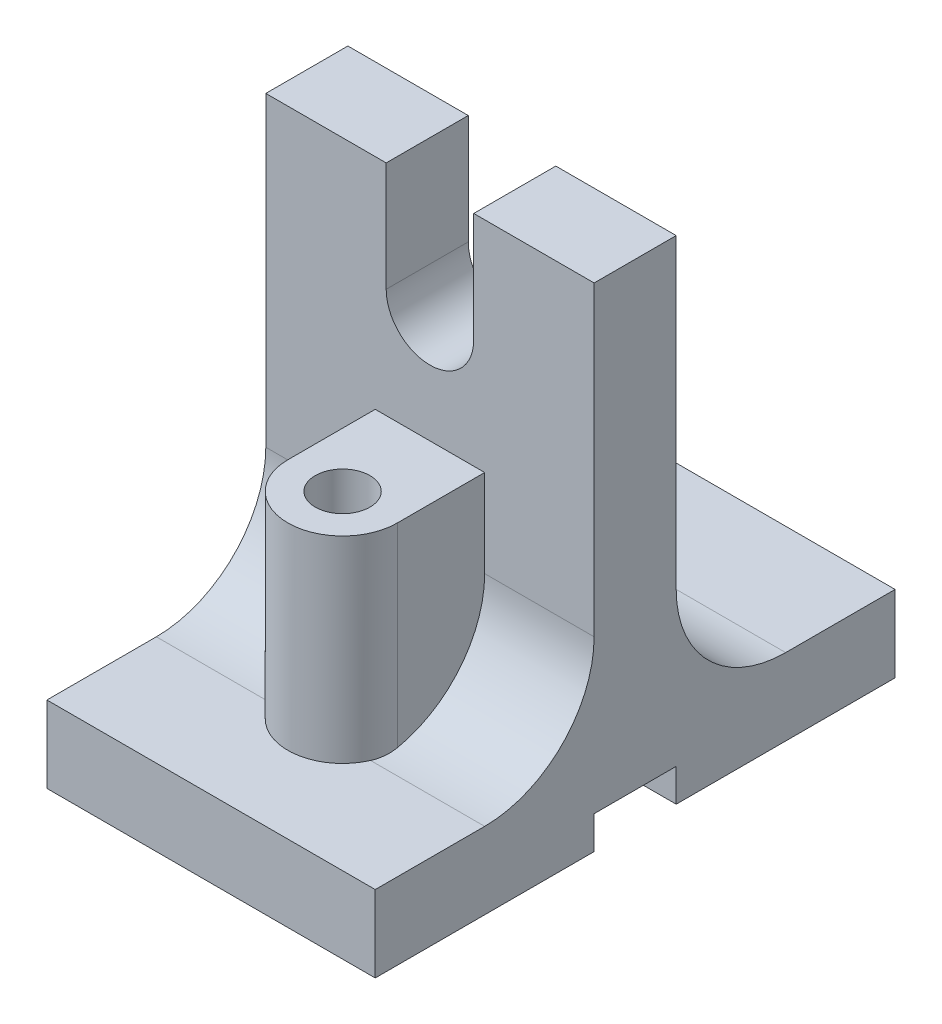
from build123d import *

# Parameters (mm, degrees)
BOSS_EXTRUDE1_DEPTH = 30
CUT_EXTRUDE1_DEPTH  = 60
SKETCH6_R           = 5
BOSS_EXTRUDE2_DEPTH = 36


with BuildPart() as part:
    # Sketch4 → Boss-Extrude1 (new body, symmetric)
    with BuildSketch(Plane(origin=(0, 0, 0), x_dir=(0, 0, -1), z_dir=(1, 0, 0))):
        with BuildLine():
            Line((-7.5, 90), (7.5, 90))
            Line((7.5, 90), (7.5, 34))
            ThreePointArc((7.5, 34), (13.357864376, 19.857864376), (27.5, 14))
            Line((27.5, 14), (47.5, 14))
            Line((47.5, 14), (47.5, 0))
            Line((47.5, 0), (7.5, 0))
            Line((7.5, 0), (7.5, 6))
            Line((7.5, 6), (-7.5, 6))
            Line((-7.5, 6), (-7.5, 0))
            Line((-7.5, 0), (-47.5, 0))
            Line((-47.5, 0), (-47.5, 14))
            Line((-47.5, 14), (-27.5, 14))
            ThreePointArc((-27.5, 14), (-13.357864376, 19.857864376), (-7.5, 34))
            Line((-7.5, 34), (-7.5, 90))
        make_face()
    extrude(amount=BOSS_EXTRUDE1_DEPTH, both=True)

    # Sketch5 → Cut-Extrude1 (cut)
    with BuildSketch(Plane.XY.offset(7.5)):
        with BuildLine():
            Line((8, 70), (8, 90))
            Line((8, 90), (-8, 90))
            Line((-8, 90), (-8, 70))
            ThreePointArc((-8, 70), (0, 62), (8, 70))
        make_face()
    extrude(amount=-CUT_EXTRUDE1_DEPTH, mode=Mode.SUBTRACT)

    # Sketch6 → Boss-Extrude2 (add)
    with BuildSketch(Plane(origin=(0, 50, 0), x_dir=(1, 0, 0), z_dir=(0, 1, 0))):
        with BuildLine():
            Line((-10, -23.46544552), (-10, -7.5))
            Line((-10, -7.5), (10, -7.5))
            Line((10, -7.5), (10, -23.46544552))
            ThreePointArc((10, -23.46544552), (0, -33.46544552), (-10, -23.46544552))
        make_face()
        with Locations((0, -23.46544552)):
            Circle(SKETCH6_R, mode=Mode.SUBTRACT)
    extrude(amount=-BOSS_EXTRUDE2_DEPTH)


solid = part.part
